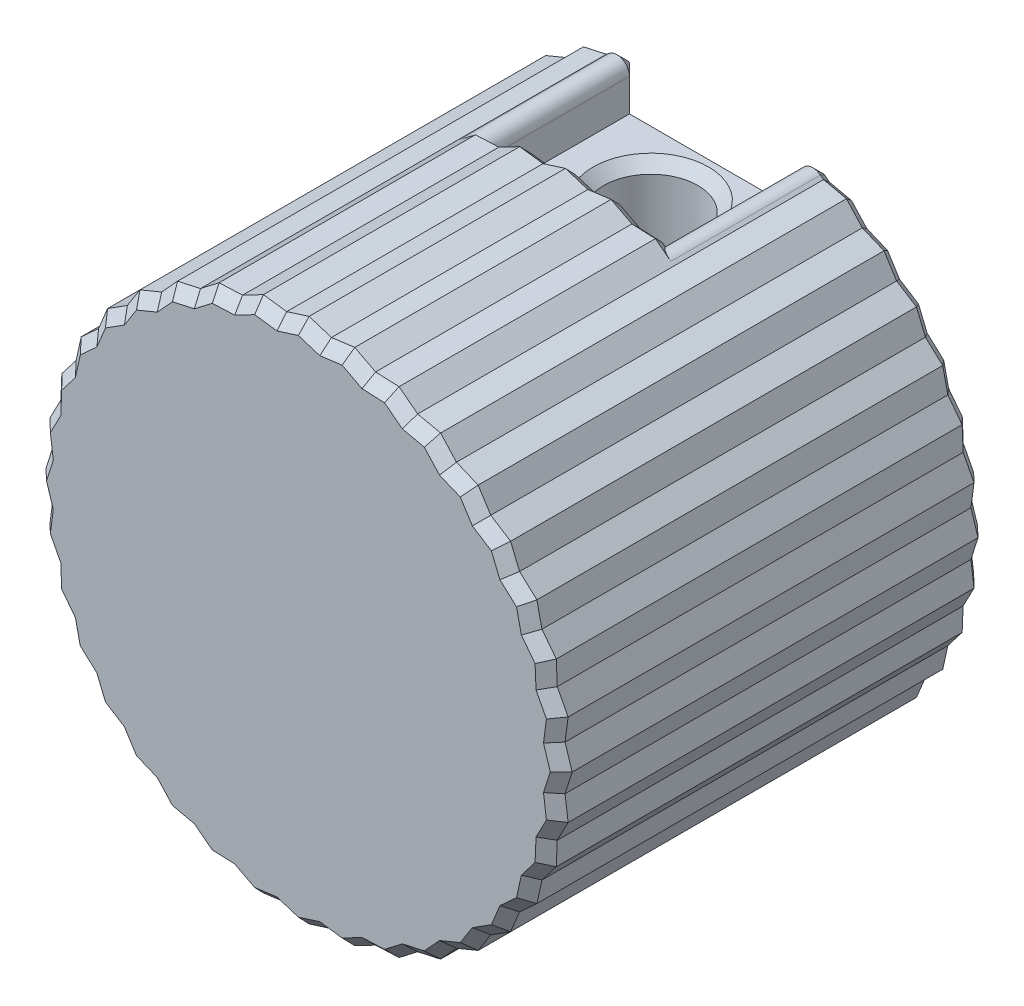
from build123d import *

# Parameters (mm, degrees)
SKETCH1_R               = 12.025
SKETCH1_R_2             = 2.65
BOSS_EXTRUDE1_DEPTH     = 20
SKETCH5_R               = 11.60821
BOSS_EXTRUDE3_DEPTH     = 20
SKETCH3_W               = 8
SKETCH3_H               = 7
CUT_EXTRUDE2_DEPTH      = 2
CUT_EXTRUDE2_DEPTH_BACK = 3
CUT_EXTRUDE1_REACH      = 26.341
SKETCH2_R               = 2.2
SKETCH4_R               = 2.65
BOSS_EXTRUDE2_DEPTH     = 2
CUT_EXTRUDE3_DEPTH      = 7
CHAMFER1_SIZE           = 0.5


with BuildPart() as part:
    # Sketch1 → Boss-Extrude1 (new body)
    with BuildSketch(Plane.XY):
        Circle(SKETCH1_R)
        Circle(SKETCH1_R_2, mode=Mode.SUBTRACT)
    extrude(amount=BOSS_EXTRUDE1_DEPTH)

    # Sketch5 → Boss-Extrude3 (add)
    with BuildSketch(Plane(origin=(0, 0, 0), x_dir=(-1, 0, 0), z_dir=(0, 0, -1))):
        Polygon((0, 12.315844), (1.048468, 11.984047), (2.138624, 12.128738), (3.113547, 11.619917), (4.212267, 11.573107), (5.084023, 10.902723), (6.157922, 10.665833), (6.900023, 9.854255), (7.916472, 9.434484), (8.50637, 8.50637), (9.434484, 7.916472), (9.854255, 6.900023), (10.665833, 6.157922), (10.902723, 5.084023), (11.573107, 4.212267), (11.619917, 3.113547), (12.128738, 2.138624), (11.984047, 1.048468), (12.315844, 0), (11.984047, -1.048468), (12.128738, -2.138624), (11.619917, -3.113547), (11.573107, -4.212267), (10.902723, -5.084023), (10.665833, -6.157922), (9.854255, -6.900023), (9.434484, -7.916472), (8.50637, -8.50637), (7.916472, -9.434484), (6.900023, -9.854255), (6.157922, -10.665833), (5.084023, -10.902723), (4.212267, -11.573107), (3.113547, -11.619917), (2.138624, -12.128738), (1.048468, -11.984047), (0, -12.315844), (-1.048468, -11.984047), (-2.138624, -12.128738), (-3.113547, -11.619917), (-4.212267, -11.573107), (-5.084023, -10.902723), (-6.157922, -10.665833), (-6.900023, -9.854255), (-7.916472, -9.434484), (-8.50637, -8.50637), (-9.434484, -7.916472), (-9.854255, -6.900023), (-10.665833, -6.157922), (-10.902723, -5.084023), (-11.573107, -4.212267), (-11.619917, -3.113547), (-12.128738, -2.138624), (-11.984047, -1.048468), (-12.315844, 0), (-11.984047, 1.048468), (-12.128738, 2.138624), (-11.619917, 3.113547), (-11.573107, 4.212267), (-10.902723, 5.084023), (-10.665833, 6.157922), (-9.854255, 6.900023), (-9.434484, 7.916472), (-8.50637, 8.50637), (-7.916472, 9.434484), (-6.900023, 9.854255), (-6.157922, 10.665833), (-5.084023, 10.902723), (-4.212267, 11.573107), (-3.113547, 11.619917), (-2.138624, 12.128738), (-1.048468, 11.984047), align=None)
        Circle(SKETCH5_R, mode=Mode.SUBTRACT)
    extrude(amount=-BOSS_EXTRUDE3_DEPTH)

    # Sketch3 → Cut-Extrude2 (cut, two sides)
    with BuildSketch(Plane(origin=(0, 12.025, 0), x_dir=(1, 0, 0), z_dir=(0, 1, 0))) as cut_extrude2_sk:
        with Locations((0, -3.5)):
            Rectangle(SKETCH3_W, SKETCH3_H)
    extrude(amount=CUT_EXTRUDE2_DEPTH, mode=Mode.SUBTRACT)
    extrude(cut_extrude2_sk.sketch, amount=-CUT_EXTRUDE2_DEPTH_BACK, mode=Mode.SUBTRACT)

    # Sketch2 → Cut-Extrude1 (cut, up to next)
    with BuildSketch(Plane(origin=(0, 12.025, 0), x_dir=(1, 0, 0), z_dir=(0, 1, 0)), mode=Mode.PRIVATE) as cut_extrude1_sk1:
        with Locations((0, -3.5)):
            Circle(SKETCH2_R)
    cut_extrude1_tool1 = extrude(cut_extrude1_sk1.sketch, amount=-CUT_EXTRUDE1_REACH, mode=Mode.PRIVATE) & part.part
    add(cut_extrude1_tool1.solids().sort_by_distance((0, 12.025, 3.5))[0], mode=Mode.SUBTRACT)

    # Sketch4 → Boss-Extrude2 (add)
    with BuildSketch(Plane.XY.offset(20)):
        Circle(SKETCH4_R)
    extrude(amount=-BOSS_EXTRUDE2_DEPTH)

    # Sketch7 → Cut-Extrude3 (cut)
    with BuildSketch(Plane(origin=(0, 0, 0), x_dir=(-1, 0, 0), z_dir=(0, 0, -1))):
        with BuildLine():
            Line((4, 10.552697), (4, 11.910466))
            Line((4, 11.910466), (4.938288, 11.014794))
            ThreePointArc((4.938288, 11.014794), (4.325384, 11.075649), (4, 10.552697))
        make_face()
        with BuildLine():
            Line((-4, 11.910466), (-4.938288, 11.014794))
            ThreePointArc((-4.938288, 11.014794), (-4.325384, 11.075649), (-4, 10.552697))
            Line((-4, 10.552697), (-4, 11.910466))
        make_face()
    extrude(amount=-CUT_EXTRUDE3_DEPTH, mode=Mode.SUBTRACT)

    # Chamfer1
    chamfer1_edges = [part.edges().sort_by_distance(p)[0] for p in [
        (0.524234, 12.149945, 20),
        (-0.524234, 12.149945, 20),
        (-1.593546, 12.056392, 20),
        (-2.626086, 11.874328, 20),
        (-3.662907, 11.596512, 20),
        (-4.648145, 11.237915, 20),
        (-5.620972, 10.784278, 20),
        (-6.528973, 10.260044, 20),
        (-7.408248, 9.644369, 20),
        (-8.211421, 8.970427, 20),
        (-8.970427, 8.211421, 20),
        (-9.644369, 7.408248, 20),
        (-10.260044, 6.528973, 20),
        (-10.784278, 5.620972, 20),
        (-11.237915, 4.648145, 20),
        (-11.596512, 3.662907, 20),
        (-11.874328, 2.626086, 20),
        (-12.056392, 1.593546, 20),
        (-12.149945, 0.524234, 20),
        (-12.149945, -0.524234, 20),
        (-12.056392, -1.593546, 20),
        (-11.874328, -2.626086, 20),
        (1.593546, 12.056392, 7),
        (-11.596512, -3.662907, 20),
        (-11.237915, -4.648145, 20),
        (-10.784278, -5.620972, 20),
        (-10.260044, -6.528973, 20),
        (-9.644369, -7.408248, 20),
        (-2.626086, 11.874328, 7),
        (-3.662907, 11.596512, 7),
        (3.662907, 11.596512, 7),
        (2.626086, 11.874328, 7),
        (0.524234, 12.149945, 7),
        (-0.524234, 12.149945, 7),
        (-1.593546, 12.056392, 7),
        (-8.970427, -8.211421, 20),
        (0, 9.025, 0),
        (-8.211421, -8.970427, 20),
        (-7.408248, -9.644369, 20),
        (-6.528973, -10.260044, 20),
        (-5.620972, -10.784278, 20),
        (-4.648145, -11.237915, 20),
        (-3.662907, -11.596512, 20),
        (-2.626086, -11.874328, 20),
        (-1.593546, -12.056392, 20),
        (-0.524234, -12.149945, 20),
        (-2.2, 9.025, 3.5),
        (0.524234, -12.149945, 20),
        (1.593546, -12.056392, 20),
        (2.626086, -11.874328, 20),
        (3.662907, -11.596512, 20),
        (4.648145, -11.237915, 20),
        (4, 9.788848, 0),
        (-4, 9.788848, 0),
        (5.620972, -10.784278, 20),
        (5.011156, 10.958758, 0),
        (6.528973, -10.260044, 20),
        (7.408248, -9.644369, 20),
        (8.211421, -8.970427, 20),
        (-4.325384, 11.075649, 0),
        (8.970427, -8.211421, 20),
        (-4.575277, 11.293951, 7),
        (9.644369, -7.408248, 20),
        (10.260044, -6.528973, 20),
        (10.784278, -5.620972, 20),
        (4.325384, 11.075649, 0),
        (4.575277, 11.293951, 7),
        (11.237915, -4.648145, 20),
        (11.596512, -3.662907, 20),
        (11.874328, -2.626086, 20),
        (12.056392, -1.593546, 20),
        (12.149945, -0.524234, 20),
        (12.149945, 0.524234, 20),
        (12.056392, 1.593546, 20),
        (11.874328, 2.626086, 20),
        (11.596512, 3.662907, 20),
        (11.237915, 4.648145, 20),
        (10.784278, 5.620972, 20),
        (10.260044, 6.528973, 20),
        (9.644369, 7.408248, 20),
        (8.970427, 8.211421, 20),
        (8.211421, 8.970427, 20),
        (7.408248, 9.644369, 20),
        (6.528973, 10.260044, 20),
        (5.620972, 10.784278, 20),
        (4.648145, 11.237915, 20),
        (3.662907, 11.596512, 20),
        (2.626086, 11.874328, 20),
        (1.593546, 12.056392, 20),
        (5.620972, 10.784278, 0),
        (6.528973, 10.260044, 0),
        (7.408248, 9.644369, 0),
        (8.211421, 8.970427, 0),
        (8.970427, 8.211421, 0),
        (9.644369, 7.408248, 0),
        (10.260044, 6.528973, 0),
        (10.784278, 5.620972, 0),
        (11.237915, 4.648145, 0),
        (11.596512, 3.662907, 0),
        (11.874328, 2.626086, 0),
        (12.056392, 1.593546, 0),
        (12.149945, 0.524234, 0),
        (12.149945, -0.524234, 0),
        (12.056392, -1.593546, 0),
        (11.874328, -2.626086, 0),
        (11.596512, -3.662907, 0),
        (11.237915, -4.648145, 0),
        (10.784278, -5.620972, 0),
        (10.260044, -6.528973, 0),
        (9.644369, -7.408248, 0),
        (8.970427, -8.211421, 0),
        (8.211421, -8.970427, 0),
        (7.408248, -9.644369, 0),
        (6.528973, -10.260044, 0),
        (5.620972, -10.784278, 0),
        (4.648145, -11.237915, 0),
        (3.662907, -11.596512, 0),
        (2.626086, -11.874328, 0),
        (1.593546, -12.056392, 0),
        (0.524234, -12.149945, 0),
        (-0.524234, -12.149945, 0),
        (-1.593546, -12.056392, 0),
        (-2.626086, -11.874328, 0),
        (-3.662907, -11.596512, 0),
        (-4.648145, -11.237915, 0),
        (-5.620972, -10.784278, 0),
        (-6.528973, -10.260044, 0),
        (-7.408248, -9.644369, 0),
        (-8.211421, -8.970427, 0),
        (-8.970427, -8.211421, 0),
        (-9.644369, -7.408248, 0),
        (-10.260044, -6.528973, 0),
        (-10.784278, -5.620972, 0),
        (-11.237915, -4.648145, 0),
        (-11.596512, -3.662907, 0),
        (-11.874328, -2.626086, 0),
        (-12.056392, -1.593546, 0),
        (-12.149945, -0.524234, 0),
        (-12.149945, 0.524234, 0),
        (-12.056392, 1.593546, 0),
        (-11.874328, 2.626086, 0),
        (-11.596512, 3.662907, 0),
        (-11.237915, 4.648145, 0),
        (-10.784278, 5.620972, 0),
        (-10.260044, 6.528973, 0),
        (-9.644369, 7.408248, 0),
        (-8.970427, 8.211421, 0),
        (-8.211421, 8.970427, 0),
        (-7.408248, 9.644369, 0),
        (-6.528973, 10.260044, 0),
        (-5.620972, 10.784278, 0),
        (-5.011156, 10.958758, 0),
        (-2.65, 0, 0),
    ]]
    chamfer(chamfer1_edges, length=CHAMFER1_SIZE)


solid = part.part
